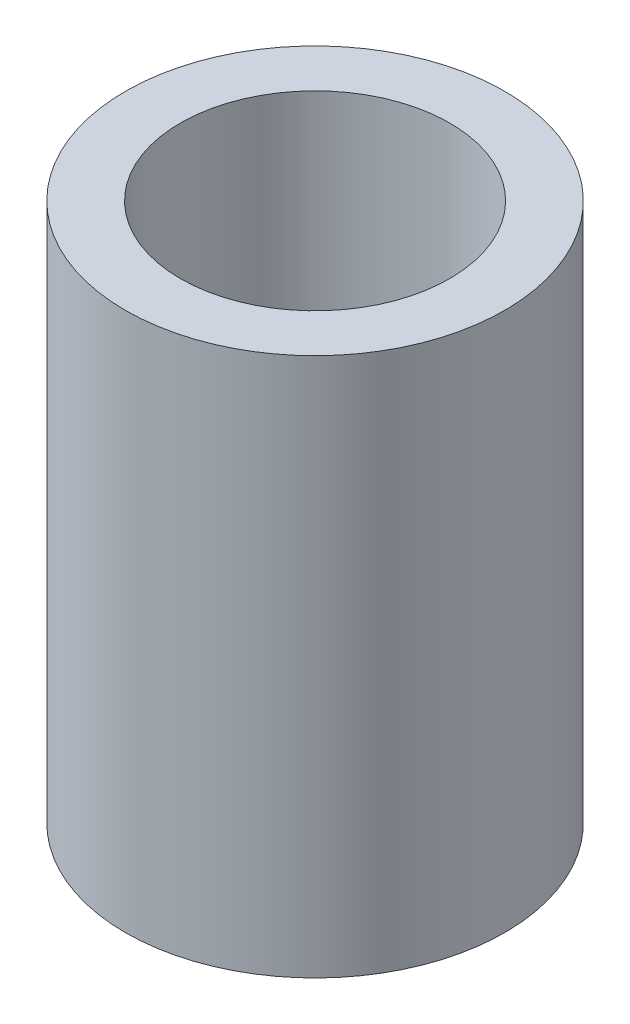
from build123d import *

# Parameters (mm, degrees)
SKETCH1_R           = 5.588
SKETCH1_R_2         = 3.96875
BOSS_EXTRUDE1_DEPTH = 15.875


with BuildPart() as part:
    # Sketch1 → Boss-Extrude1 (new body)
    with BuildSketch(Plane(origin=(0, 0, 0), x_dir=(1, 0, 0), z_dir=(0, 1, 0))):
        Circle(SKETCH1_R)
        Circle(SKETCH1_R_2, mode=Mode.SUBTRACT)
    extrude(amount=BOSS_EXTRUDE1_DEPTH)


solid = part.part
